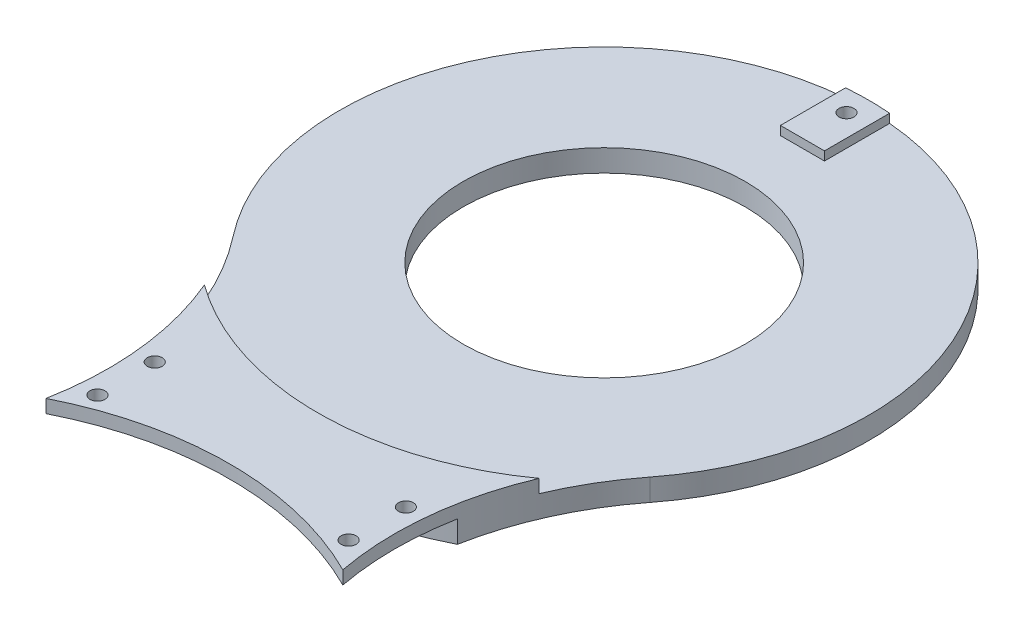
from build123d import *

# Parameters (mm, degrees)
CROQUIS1_R              = 32
SALIENTE_EXTRUIR1_DEPTH = 5
SALIENTE_EXTRUIR2_DEPTH = 2
CROQUIS3_R              = 1.7
CORTAR_EXTRUIR1_DEPTH   = 19
CROQUIS4_R              = 2.95
CORTAR_EXTRUIR2_DEPTH   = 3
CROQUIS5_R              = 1.7
CORTAR_EXTRUIR3_DEPTH   = 5
CORTAR_EXTRUIR5_DEPTH   = 37
CROQUIS7_R              = 1.7
SALIENTE_EXTRUIR3_DEPTH = 3


with BuildPart() as part:
    # Croquis1 → Saliente-Extruir1 (new body)
    with BuildSketch(Plane(origin=(0, 0, 0), x_dir=(1, 0, 0), z_dir=(0, 1, 0))):
        with BuildLine():
            ThreePointArc((-47.29361892, 36.923076923), (0, -60), (47.29361892, 36.923076923))
            ThreePointArc((47.29361892, 36.923076923), (32.46950766, 80), (47.29361892, 123.076923077))
            ThreePointArc((47.29361892, 123.076923077), (0, 220), (-47.29361892, 123.076923077))
            ThreePointArc((-47.29361892, 123.076923077), (-32.46950766, 80), (-47.29361892, 36.923076923))
        make_face()
        Circle(CROQUIS1_R, mode=Mode.SUBTRACT)
        with Locations((0, 160)):
            Circle(CROQUIS1_R, mode=Mode.SUBTRACT)
    extrude(amount=SALIENTE_EXTRUIR1_DEPTH)

    # Croquis2 → Saliente-Extruir2 (add)
    with BuildSketch(Plane(origin=(0, 5, 0), x_dir=(1, 0, 0), z_dir=(0, 1, 0))):
        with BuildLine():
            Line((5, 205), (-5, 205))
            Line((-5, 205), (-5, 219.791303716))
            ThreePointArc((-5, 219.791303716), (0, 220), (5, 219.791303716))
            Line((5, 219.791303716), (5, 205))
        make_face()
        with BuildLine():
            Line((-5, -45), (5, -45))
            Line((5, -45), (5, -59.791303716))
            ThreePointArc((5, -59.791303716), (0, -60), (-5, -59.791303716))
            Line((-5, -59.791303716), (-5, -45))
        make_face()
    extrude(amount=SALIENTE_EXTRUIR2_DEPTH)

    # Croquis3 → Cortar-Extruir1 (cut)
    with BuildSketch(Plane(origin=(0, 7, 0), x_dir=(1, 0, 0), z_dir=(0, 1, 0))):
        with Locations((0, 215)):
            Circle(CROQUIS3_R)
        with Locations((0, -55)):
            Circle(CROQUIS3_R)
    extrude(amount=-CORTAR_EXTRUIR1_DEPTH, mode=Mode.SUBTRACT)

    # Croquis4 → Cortar-Extruir2 (cut)
    with BuildSketch(Plane.XZ):
        with Locations((0, 55)):
            Circle(CROQUIS4_R)
        with Locations((0, -215)):
            Circle(CROQUIS4_R)
    extrude(amount=-CORTAR_EXTRUIR2_DEPTH, mode=Mode.SUBTRACT)

    # Croquis5 → Cortar-Extruir3 (cut)
    with BuildSketch(Plane.XZ):
        with Locations((-28.5, -73.5)):
            Circle(CROQUIS5_R)
        with Locations((-28.5, -86.5)):
            Circle(CROQUIS5_R)
        with Locations((28.5, -86.5)):
            Circle(CROQUIS5_R)
        with Locations((28.5, -73.5)):
            Circle(CROQUIS5_R)
    extrude(amount=-CORTAR_EXTRUIR3_DEPTH, mode=Mode.SUBTRACT)

    # Croquis6 → Cortar-Extruir5 (cut)
    with BuildSketch(Plane.XZ):
        with BuildLine():
            Line((65, 77.416573868), (-65, 77.416573868))
            Line((-65, 77.416573868), (-65, -122.583426132))
            ThreePointArc((-65, -122.583426132), (0, -85), (65, -122.583426132))
            Line((65, -122.583426132), (65, 77.416573868))
        make_face()
    extrude(amount=-CORTAR_EXTRUIR5_DEPTH, mode=Mode.SUBTRACT)

    # Croquis7 → Saliente-Extruir3 (add)
    with BuildSketch(Plane(origin=(0, 5, 0), x_dir=(1, 0, 0), z_dir=(0, 1, 0))):
        with BuildLine():
            ThreePointArc((37.996513473, 107.262300355), (32.867557136, 87.454427095), (33.685420375, 67.009644486))
            ThreePointArc((33.685420375, 67.009644486), (0, 75), (-33.685420375, 67.009644486))
            ThreePointArc((-33.685420375, 67.009644486), (-32.867557136, 87.454427095), (-37.996513473, 107.262300355))
            ThreePointArc((-37.996513473, 107.262300355), (0, 95), (37.996513473, 107.262300355))
        make_face()
        with Locations((-28.5, 86.5)):
            Circle(CROQUIS7_R, mode=Mode.SUBTRACT)
        with Locations((-28.5, 73.5)):
            Circle(CROQUIS7_R, mode=Mode.SUBTRACT)
        with Locations((28.5, 73.5)):
            Circle(CROQUIS7_R, mode=Mode.SUBTRACT)
        with Locations((28.5, 86.5)):
            Circle(CROQUIS7_R, mode=Mode.SUBTRACT)
    extrude(amount=SALIENTE_EXTRUIR3_DEPTH)


solid = part.part
